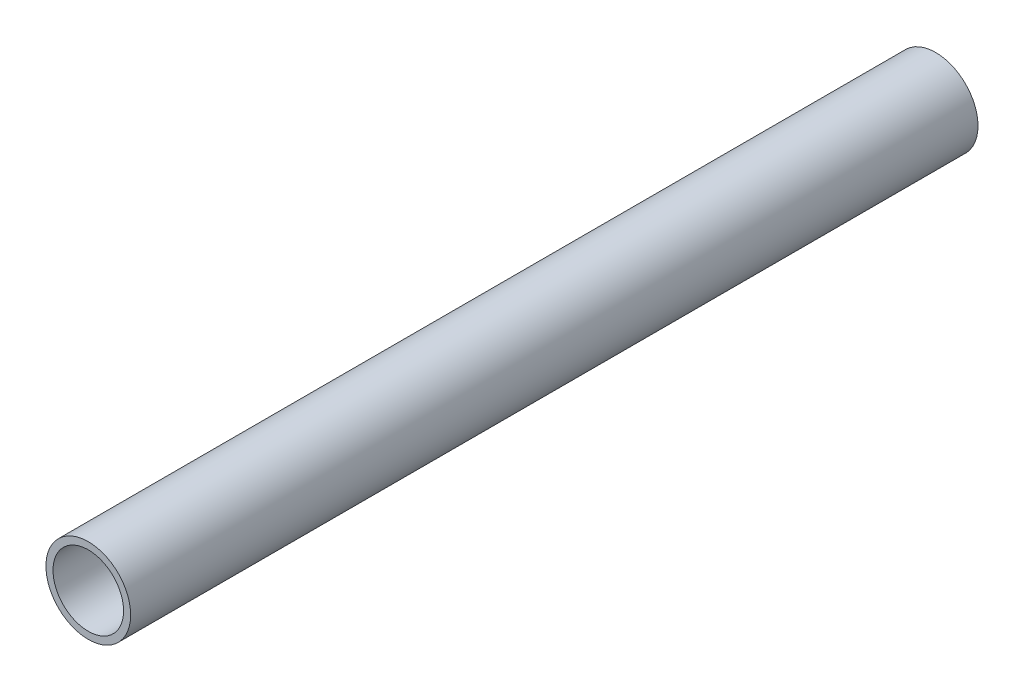
from build123d import *

# Parameters (mm, degrees)
SKETCH1_R           = 3
SKETCH1_R_2         = 2.5
BOSS_EXTRUDE1_DEPTH = 60


with BuildPart() as part:
    # Sketch1 → Boss-Extrude1 (new body)
    with BuildSketch(Plane.XY):
        Circle(SKETCH1_R)
        Circle(SKETCH1_R_2, mode=Mode.SUBTRACT)
    extrude(amount=BOSS_EXTRUDE1_DEPTH)


solid = part.part
